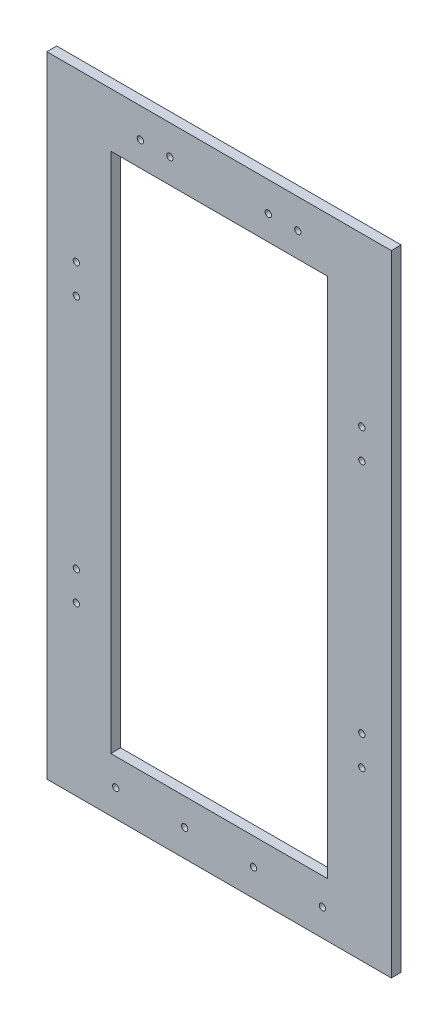
from build123d import *

# Parameters (mm, degrees)
SKETCH1_W                      = 175
SKETCH1_H                      = 320
BOSS_EXTRUDE1_DEPTH            = 5
CUT_EXTRUDE1_REACH             = 7
SKETCH2_W                      = 110
SKETCH2_H                      = 265
CUT_EXTRUDE2_REACH             = 7
SKETCH4_R                      = 1.6
CUT_EXTRUDE3_REACH             = 7
SKETCH5_R                      = 1.6
CUT_EXTRUDE4_REACH             = 7
SKETCH6_R                      = 1.6
CUT_EXTRUDE4_DIRECTION_2_DEPTH = 1


with BuildPart() as part:
    # Sketch1 → Boss-Extrude1 (new body)
    with BuildSketch(Plane.XY):
        Rectangle(SKETCH1_W, SKETCH1_H)
    extrude(amount=BOSS_EXTRUDE1_DEPTH)

    # Sketch2 → Cut-Extrude1 (cut, up to next)
    with BuildSketch(Plane(origin=(0, 0, 0), x_dir=(-1, 0, 0), z_dir=(0, 0, -1)), mode=Mode.PRIVATE) as cut_extrude1_sk1:
        Rectangle(SKETCH2_W, SKETCH2_H)
    cut_extrude1_tool1 = extrude(cut_extrude1_sk1.sketch, amount=-CUT_EXTRUDE1_REACH, mode=Mode.PRIVATE) & part.part
    add(cut_extrude1_tool1.solids().sort_by_distance((0, 0, 0))[0], mode=Mode.SUBTRACT)

    # Sketch4 → Cut-Extrude2 (cut, up to next)
    with BuildSketch(Plane(origin=(0, 0, 0), x_dir=(-1, 0, 0), z_dir=(0, 0, -1)), mode=Mode.PRIVATE) as cut_extrude2_sk1:
        with Locations((-25, 145)):
            Circle(SKETCH4_R)
    cut_extrude2_tool1 = extrude(cut_extrude2_sk1.sketch, amount=-CUT_EXTRUDE2_REACH, mode=Mode.PRIVATE) & part.part
    add(cut_extrude2_tool1.solids().sort_by_distance((25, 145, 0))[0], mode=Mode.SUBTRACT)
    # Sketch4 → Cut-Extrude2 (cut, up to next)
    with BuildSketch(Plane(origin=(0, 0, 0), x_dir=(-1, 0, 0), z_dir=(0, 0, -1)), mode=Mode.PRIVATE) as cut_extrude2_sk2:
        with Locations((-40, 145)):
            Circle(SKETCH4_R)
    cut_extrude2_tool2 = extrude(cut_extrude2_sk2.sketch, amount=-CUT_EXTRUDE2_REACH, mode=Mode.PRIVATE) & part.part
    add(cut_extrude2_tool2.solids().sort_by_distance((40, 145, 0))[0], mode=Mode.SUBTRACT)
    # Sketch4 → Cut-Extrude2 (cut, up to next)
    with BuildSketch(Plane(origin=(0, 0, 0), x_dir=(-1, 0, 0), z_dir=(0, 0, -1)), mode=Mode.PRIVATE) as cut_extrude2_sk3:
        with Locations((25, 145)):
            Circle(SKETCH4_R)
    cut_extrude2_tool3 = extrude(cut_extrude2_sk3.sketch, amount=-CUT_EXTRUDE2_REACH, mode=Mode.PRIVATE) & part.part
    add(cut_extrude2_tool3.solids().sort_by_distance((-25, 145, 0))[0], mode=Mode.SUBTRACT)
    # Sketch4 → Cut-Extrude2 (cut, up to next)
    with BuildSketch(Plane(origin=(0, 0, 0), x_dir=(-1, 0, 0), z_dir=(0, 0, -1)), mode=Mode.PRIVATE) as cut_extrude2_sk4:
        with Locations((40, 145)):
            Circle(SKETCH4_R)
    cut_extrude2_tool4 = extrude(cut_extrude2_sk4.sketch, amount=-CUT_EXTRUDE2_REACH, mode=Mode.PRIVATE) & part.part
    add(cut_extrude2_tool4.solids().sort_by_distance((-40, 145, 0))[0], mode=Mode.SUBTRACT)

    # Sketch5 → Cut-Extrude3 (cut, up to next)
    with BuildSketch(Plane(origin=(0, 0, 0), x_dir=(-1, 0, 0), z_dir=(0, 0, -1)), mode=Mode.PRIVATE) as cut_extrude3_sk1:
        with Locations((-72.5, 75)):
            Circle(SKETCH5_R)
    cut_extrude3_tool1 = extrude(cut_extrude3_sk1.sketch, amount=-CUT_EXTRUDE3_REACH, mode=Mode.PRIVATE) & part.part
    add(cut_extrude3_tool1.solids().sort_by_distance((72.5, 75, 0))[0], mode=Mode.SUBTRACT)
    # Sketch5 → Cut-Extrude3 (cut, up to next)
    with BuildSketch(Plane(origin=(0, 0, 0), x_dir=(-1, 0, 0), z_dir=(0, 0, -1)), mode=Mode.PRIVATE) as cut_extrude3_sk2:
        with Locations((-72.5, 60)):
            Circle(SKETCH5_R)
    cut_extrude3_tool2 = extrude(cut_extrude3_sk2.sketch, amount=-CUT_EXTRUDE3_REACH, mode=Mode.PRIVATE) & part.part
    add(cut_extrude3_tool2.solids().sort_by_distance((72.5, 60, 0))[0], mode=Mode.SUBTRACT)
    # Sketch5 → Cut-Extrude3 (cut, up to next)
    with BuildSketch(Plane(origin=(0, 0, 0), x_dir=(-1, 0, 0), z_dir=(0, 0, -1)), mode=Mode.PRIVATE) as cut_extrude3_sk3:
        with Locations((-72.5, -75)):
            Circle(SKETCH5_R)
    cut_extrude3_tool3 = extrude(cut_extrude3_sk3.sketch, amount=-CUT_EXTRUDE3_REACH, mode=Mode.PRIVATE) & part.part
    add(cut_extrude3_tool3.solids().sort_by_distance((72.5, -75, 0))[0], mode=Mode.SUBTRACT)
    # Sketch5 → Cut-Extrude3 (cut, up to next)
    with BuildSketch(Plane(origin=(0, 0, 0), x_dir=(-1, 0, 0), z_dir=(0, 0, -1)), mode=Mode.PRIVATE) as cut_extrude3_sk4:
        with Locations((-72.5, -60)):
            Circle(SKETCH5_R)
    cut_extrude3_tool4 = extrude(cut_extrude3_sk4.sketch, amount=-CUT_EXTRUDE3_REACH, mode=Mode.PRIVATE) & part.part
    add(cut_extrude3_tool4.solids().sort_by_distance((72.5, -60, 0))[0], mode=Mode.SUBTRACT)
    # Sketch5 → Cut-Extrude3 (cut, up to next)
    with BuildSketch(Plane(origin=(0, 0, 0), x_dir=(-1, 0, 0), z_dir=(0, 0, -1)), mode=Mode.PRIVATE) as cut_extrude3_sk5:
        with Locations((72.5, -75)):
            Circle(SKETCH5_R)
    cut_extrude3_tool5 = extrude(cut_extrude3_sk5.sketch, amount=-CUT_EXTRUDE3_REACH, mode=Mode.PRIVATE) & part.part
    add(cut_extrude3_tool5.solids().sort_by_distance((-72.5, -75, 0))[0], mode=Mode.SUBTRACT)
    # Sketch5 → Cut-Extrude3 (cut, up to next)
    with BuildSketch(Plane(origin=(0, 0, 0), x_dir=(-1, 0, 0), z_dir=(0, 0, -1)), mode=Mode.PRIVATE) as cut_extrude3_sk6:
        with Locations((72.5, -60)):
            Circle(SKETCH5_R)
    cut_extrude3_tool6 = extrude(cut_extrude3_sk6.sketch, amount=-CUT_EXTRUDE3_REACH, mode=Mode.PRIVATE) & part.part
    add(cut_extrude3_tool6.solids().sort_by_distance((-72.5, -60, 0))[0], mode=Mode.SUBTRACT)
    # Sketch5 → Cut-Extrude3 (cut, up to next)
    with BuildSketch(Plane(origin=(0, 0, 0), x_dir=(-1, 0, 0), z_dir=(0, 0, -1)), mode=Mode.PRIVATE) as cut_extrude3_sk7:
        with Locations((72.5, 60)):
            Circle(SKETCH5_R)
    cut_extrude3_tool7 = extrude(cut_extrude3_sk7.sketch, amount=-CUT_EXTRUDE3_REACH, mode=Mode.PRIVATE) & part.part
    add(cut_extrude3_tool7.solids().sort_by_distance((-72.5, 60, 0))[0], mode=Mode.SUBTRACT)
    # Sketch5 → Cut-Extrude3 (cut, up to next)
    with BuildSketch(Plane(origin=(0, 0, 0), x_dir=(-1, 0, 0), z_dir=(0, 0, -1)), mode=Mode.PRIVATE) as cut_extrude3_sk8:
        with Locations((72.5, 75)):
            Circle(SKETCH5_R)
    cut_extrude3_tool8 = extrude(cut_extrude3_sk8.sketch, amount=-CUT_EXTRUDE3_REACH, mode=Mode.PRIVATE) & part.part
    add(cut_extrude3_tool8.solids().sort_by_distance((-72.5, 75, 0))[0], mode=Mode.SUBTRACT)

    # Sketch6 → Cut-Extrude4 (cut, up to next)
    with BuildSketch(Plane(origin=(0, 0, 0), x_dir=(-1, 0, 0), z_dir=(0, 0, -1)), mode=Mode.PRIVATE) as cut_extrude4_sk1:
        with Locations((52.5, -146.25)):
            Circle(SKETCH6_R)
    cut_extrude4_tool1 = extrude(cut_extrude4_sk1.sketch, amount=-CUT_EXTRUDE4_REACH, mode=Mode.PRIVATE) & part.part
    add(cut_extrude4_tool1.solids().sort_by_distance((-52.5, -146.25, 0))[0], mode=Mode.SUBTRACT)
    # Sketch6 → Cut-Extrude4 (cut, up to next)
    with BuildSketch(Plane(origin=(0, 0, 0), x_dir=(-1, 0, 0), z_dir=(0, 0, -1)), mode=Mode.PRIVATE) as cut_extrude4_sk2:
        with Locations((17.5, -146.25)):
            Circle(SKETCH6_R)
    cut_extrude4_tool2 = extrude(cut_extrude4_sk2.sketch, amount=-CUT_EXTRUDE4_REACH, mode=Mode.PRIVATE) & part.part
    add(cut_extrude4_tool2.solids().sort_by_distance((-17.5, -146.25, 0))[0], mode=Mode.SUBTRACT)
    # Sketch6 → Cut-Extrude4 (cut, up to next)
    with BuildSketch(Plane(origin=(0, 0, 0), x_dir=(-1, 0, 0), z_dir=(0, 0, -1)), mode=Mode.PRIVATE) as cut_extrude4_sk3:
        with Locations((-17.5, -146.25)):
            Circle(SKETCH6_R)
    cut_extrude4_tool3 = extrude(cut_extrude4_sk3.sketch, amount=-CUT_EXTRUDE4_REACH, mode=Mode.PRIVATE) & part.part
    add(cut_extrude4_tool3.solids().sort_by_distance((17.5, -146.25, 0))[0], mode=Mode.SUBTRACT)
    # Sketch6 → Cut-Extrude4 (cut, up to next)
    with BuildSketch(Plane(origin=(0, 0, 0), x_dir=(-1, 0, 0), z_dir=(0, 0, -1)), mode=Mode.PRIVATE) as cut_extrude4_sk4:
        with Locations((-52.5, -146.25)):
            Circle(SKETCH6_R)
    cut_extrude4_tool4 = extrude(cut_extrude4_sk4.sketch, amount=-CUT_EXTRUDE4_REACH, mode=Mode.PRIVATE) & part.part
    add(cut_extrude4_tool4.solids().sort_by_distance((52.5, -146.25, 0))[0], mode=Mode.SUBTRACT)

    # Sketch6 → Cut-Extrude4 direction 2 (cut)
    with BuildSketch(Plane(origin=(0, 0, 0), x_dir=(-1, 0, 0), z_dir=(0, 0, -1))):
        with Locations((52.5, -146.25)):
            Circle(SKETCH6_R)
        with Locations((17.5, -146.25)):
            Circle(SKETCH6_R)
        with Locations((-17.5, -146.25)):
            Circle(SKETCH6_R)
        with Locations((-52.5, -146.25)):
            Circle(SKETCH6_R)
    extrude(amount=CUT_EXTRUDE4_DIRECTION_2_DEPTH, mode=Mode.SUBTRACT)


solid = part.part
